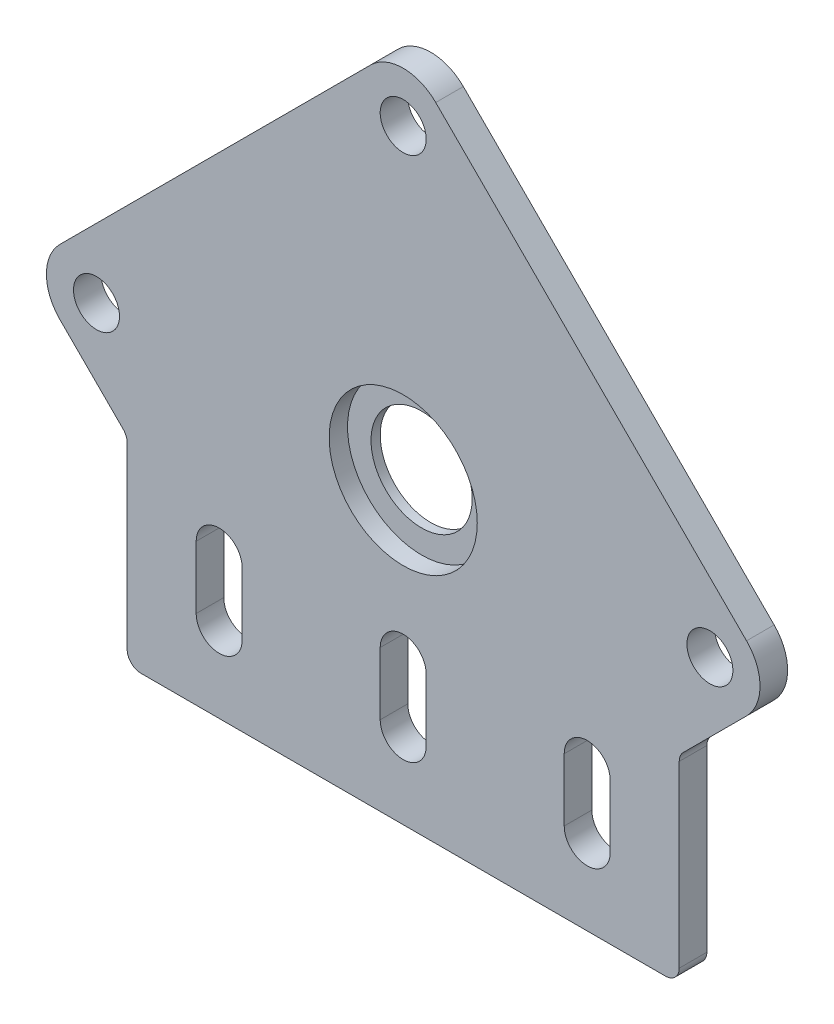
from build123d import *

# Parameters (mm, degrees)
MODEL_R             = 5.5
MODEL_R_2           = 2.5
BOSS_EXTRUDE1_DEPTH = 3
SKETCH2_R           = 8.05
CUT_EXTRUDE1_DEPTH  = 2


with BuildPart() as part:
    # Model → Boss-Extrude1 (new body)
    with BuildSketch(Plane.XY):
        with BuildLine():
            Line((-28.5, 0), (28.5, 0))
            ThreePointArc((28.5, 0), (29.560660172, 0.439339828), (30, 1.5))
            Line((30, 1.5), (30, 20.959120907))
            ThreePointArc((30, 20.959120907), (30.114180701, 21.533146056), (30.439339828, 22.019781079))
            Line((30.439339828, 22.019781079), (37.314024843, 28.894466094))
            ThreePointArc((37.314024843, 28.894466094), (38.778490937, 32.43), (37.314024843, 35.965533906))
            Line((37.314024843, 35.965533906), (3.535533906, 69.744024843))
            ThreePointArc((3.535533906, 69.744024843), (0, 71.208490937), (-3.535533906, 69.744024843))
            Line((-3.535533906, 69.744024843), (-37.314024843, 35.965533906))
            ThreePointArc((-37.314024843, 35.965533906), (-38.778490937, 32.43), (-37.314024843, 28.894466094))
            Line((-37.314024843, 28.894466094), (-30.439339828, 22.019781079))
            ThreePointArc((-30.439339828, 22.019781079), (-30.114180701, 21.533146056), (-30, 20.959120907))
            Line((-30, 20.959120907), (-30, 1.5))
            ThreePointArc((-30, 1.5), (-29.560660172, 0.439339828), (-28.5, 0))
        make_face()
        with Locations((0, 32.43)):
            Circle(MODEL_R, mode=Mode.SUBTRACT)
        with Locations((0, 65.76302733)):
            Circle(MODEL_R_2, mode=Mode.SUBTRACT)
        with Locations((33.333, 32.43)):
            Circle(MODEL_R_2, mode=Mode.SUBTRACT)
        with Locations((-33.333, 32.43)):
            Circle(MODEL_R_2, mode=Mode.SUBTRACT)
        with BuildLine():
            Line((22.5, 8.63), (22.5, 15.43))
            ThreePointArc((22.5, 15.43), (20, 17.93), (17.5, 15.43))
            Line((17.5, 15.43), (17.5, 8.63))
            ThreePointArc((17.5, 8.63), (20, 6.13), (22.5, 8.63))
        make_face(mode=Mode.SUBTRACT)
        with BuildLine():
            Line((-22.5, 8.63), (-22.5, 15.43))
            ThreePointArc((-22.5, 15.43), (-20, 17.93), (-17.5, 15.43))
            Line((-17.5, 15.43), (-17.5, 8.63))
            ThreePointArc((-17.5, 8.63), (-20, 6.13), (-22.5, 8.63))
        make_face(mode=Mode.SUBTRACT)
        with BuildLine():
            Line((-2.5, 8.63), (-2.5, 15.43))
            ThreePointArc((-2.5, 15.43), (0, 17.93), (2.5, 15.43))
            Line((2.5, 15.43), (2.5, 8.63))
            ThreePointArc((2.5, 8.63), (0, 6.13), (-2.5, 8.63))
        make_face(mode=Mode.SUBTRACT)
    extrude(amount=BOSS_EXTRUDE1_DEPTH)

    # Sketch2 → Cut-Extrude1 (cut)
    with BuildSketch(Plane.XY.offset(3)):
        with Locations((0, 32.43)):
            Circle(SKETCH2_R)
    extrude(amount=-CUT_EXTRUDE1_DEPTH, mode=Mode.SUBTRACT)


solid = part.part
